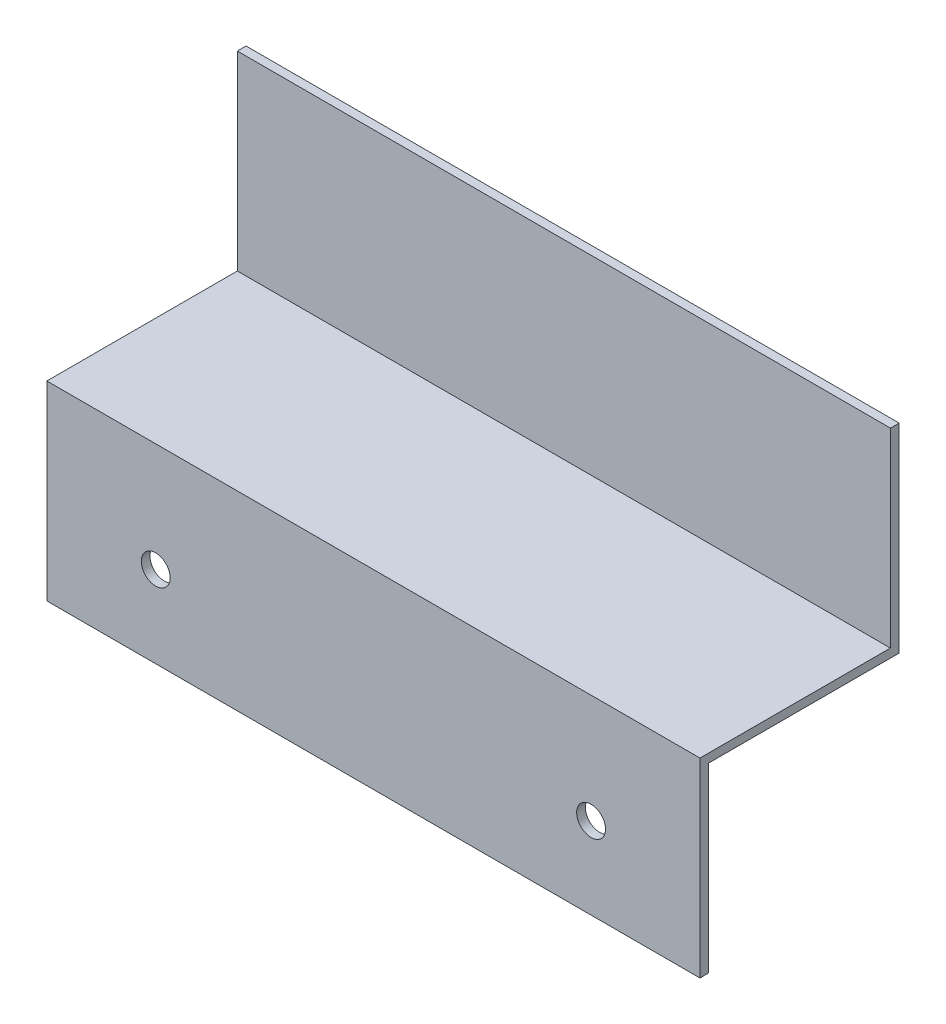
from build123d import *

# Parameters (mm, degrees)
BOSS_EXTRUDE1_DEPTH = 152.4
SKETCH2_R           = 3.3655
CUT_EXTRUDE1_DEPTH  = 47.482


with BuildPart() as part:
    # Sketch1 → Boss-Extrude1 (new body)
    with BuildSketch(Plane(origin=(0, 0, 0), x_dir=(0, 0, -1), z_dir=(1, 0, 0))):
        Polygon((0, 0), (0, -44.45), (-44.45, -44.45), (-44.45, -88.9), (-42.418, -88.9), (-42.418, -46.482), (2.032, -46.482), (2.032, 0), align=None)
    extrude(amount=BOSS_EXTRUDE1_DEPTH)

    # Sketch2 → Cut-Extrude1 (cut, through all)
    with BuildSketch(Plane.XY.offset(44.45)):
        with Locations((25.4, -69.85)):
            Circle(SKETCH2_R)
        with Locations((127, -69.85)):
            Circle(SKETCH2_R)
    extrude(amount=-CUT_EXTRUDE1_DEPTH, mode=Mode.SUBTRACT)


solid = part.part
